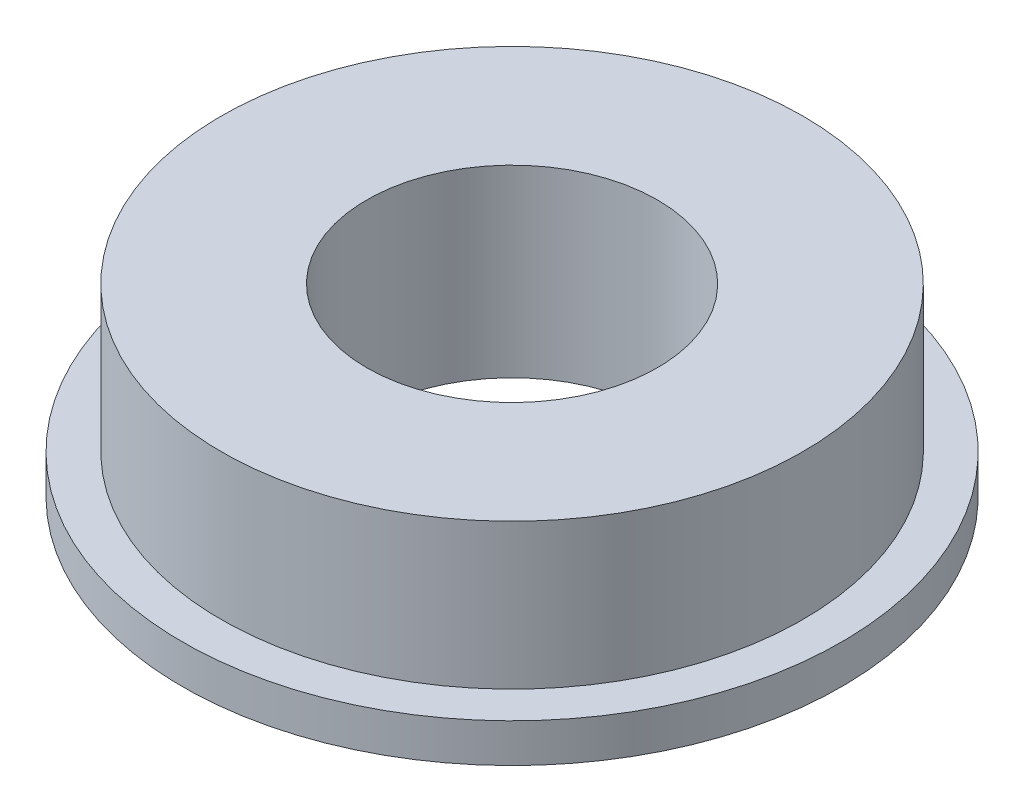
from build123d import *


with BuildPart() as part:
    # 草图1 → 旋转1 (revolve)
    with BuildSketch(Plane.XY):
        Polygon((-3, 3.8), (-3, 0), (-6.8, 0), (-6.8, 0.8), (-6, 0.8), (-6, 3.8), align=None)
    revolve(axis=Axis((0, 0, 0), (0, 1, 0)))


solid = part.part
